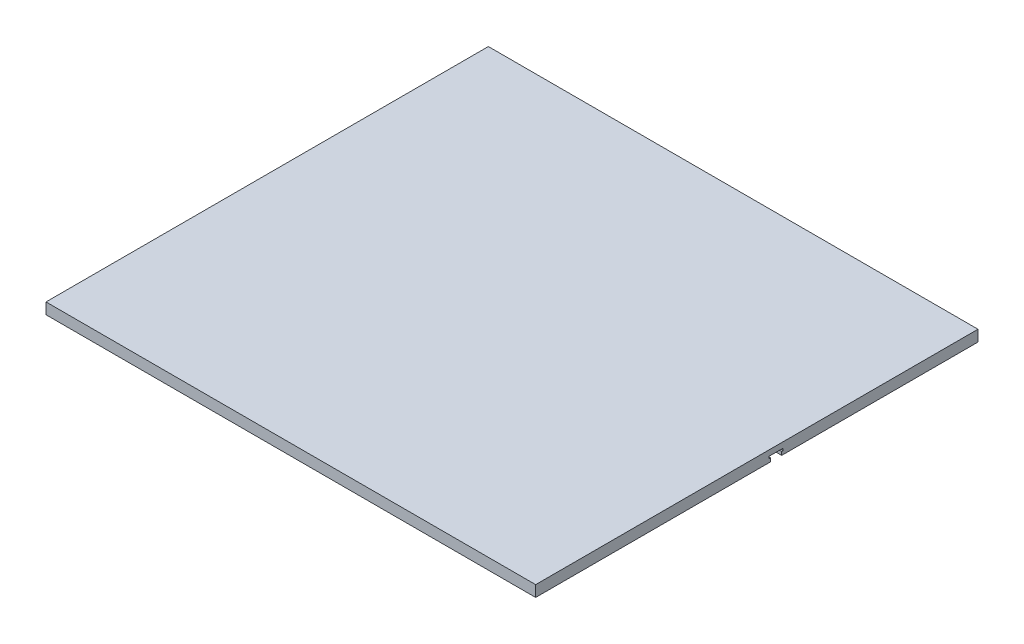
from build123d import *

# Parameters (mm, degrees)
SKETCH1_W           = 838.2
SKETCH1_H           = 757.2375
BOSS_EXTRUDE1_DEPTH = 19.05
CUT_EXTRUDE1_DEPTH  = 839.2


with BuildPart() as part:
    # Sketch1 → Boss-Extrude1 (new body)
    with BuildSketch(Plane(origin=(0, 0, 0), x_dir=(1, 0, 0), z_dir=(0, 1, 0))):
        with Locations((419.1, 378.61875)):
            Rectangle(SKETCH1_W, SKETCH1_H)
    extrude(amount=BOSS_EXTRUDE1_DEPTH)

    # Sketch3 → Cut-Extrude1 (cut, through all)
    with BuildSketch(Plane(origin=(838.2, 0, 0), x_dir=(0, 0, -1), z_dir=(1, 0, 0))):
        Polygon((421.17645, 0), (421.17645, 5.96265), (423.84345, 5.96265), (423.84345, 9.51865), (399.45945, 9.51865), (399.45945, 5.96265), (402.12645, 5.96265), (402.12645, 0), align=None)
    extrude(amount=-CUT_EXTRUDE1_DEPTH, mode=Mode.SUBTRACT)


solid = part.part
